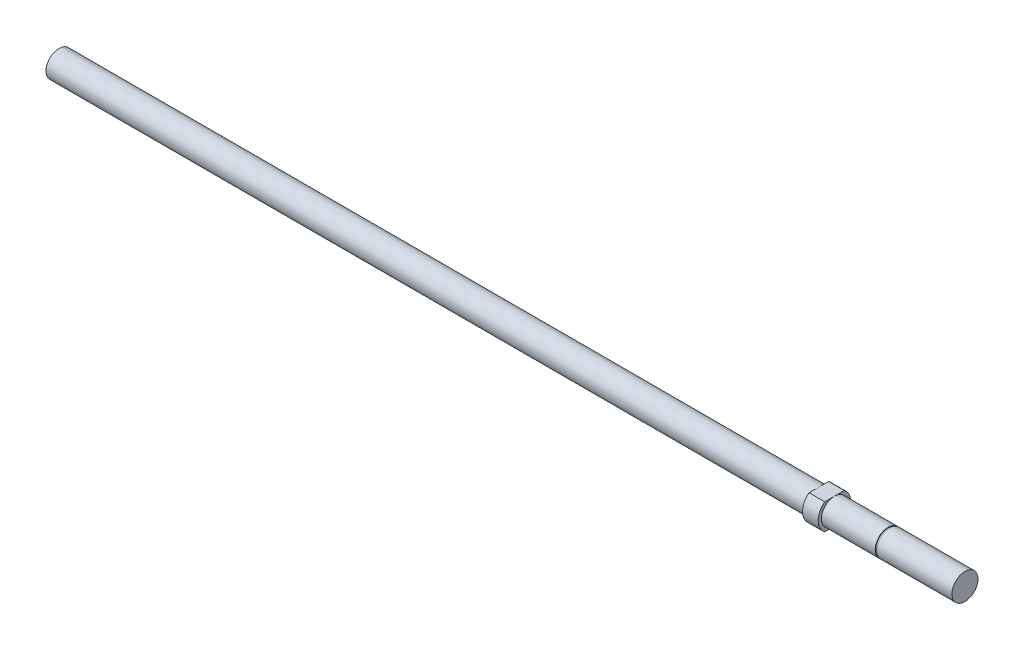
from build123d import *

# Parameters (mm, degrees)
SKETCH2_OUTSIDE_W   = 54.09
SKETCH2_OUTSIDE_H   = 54.09
SKETCH2_OUTSIDE_W_2 = 7.9375
SKETCH2_OUTSIDE_H_2 = 6.35
CUT_EXTRUDE1_DEPTH  = 221.543430501


with BuildPart() as part:
    # Sketch1 → Revolve1 (revolve)
    with BuildSketch(Plane.XY):
        Polygon((0, 0), (-220.472, 0), (-220.472, 3.175), (-35.56, 3.175), (-35.56, 3.96875), (-31.75, 3.96875), (-31.75, 3.175), (-18.669, 3.175), (-18.669, 3.0226), (-18.288, 3.0226), (-18.288, 3.175), (0, 3.175), align=None)
    revolve(axis=Axis((0, 0, 0), (-1, 0, 0)))

    # Sketch2 outside → Cut-Extrude1 (cut, through all)
    with BuildSketch(Plane(origin=(0, 0, 0), x_dir=(0, 0, -1), z_dir=(1, 0, 0))):
        Rectangle(SKETCH2_OUTSIDE_W, SKETCH2_OUTSIDE_H)
        Rectangle(SKETCH2_OUTSIDE_W_2, SKETCH2_OUTSIDE_H_2, mode=Mode.SUBTRACT)
    extrude(amount=-CUT_EXTRUDE1_DEPTH, mode=Mode.SUBTRACT)


solid = part.part
